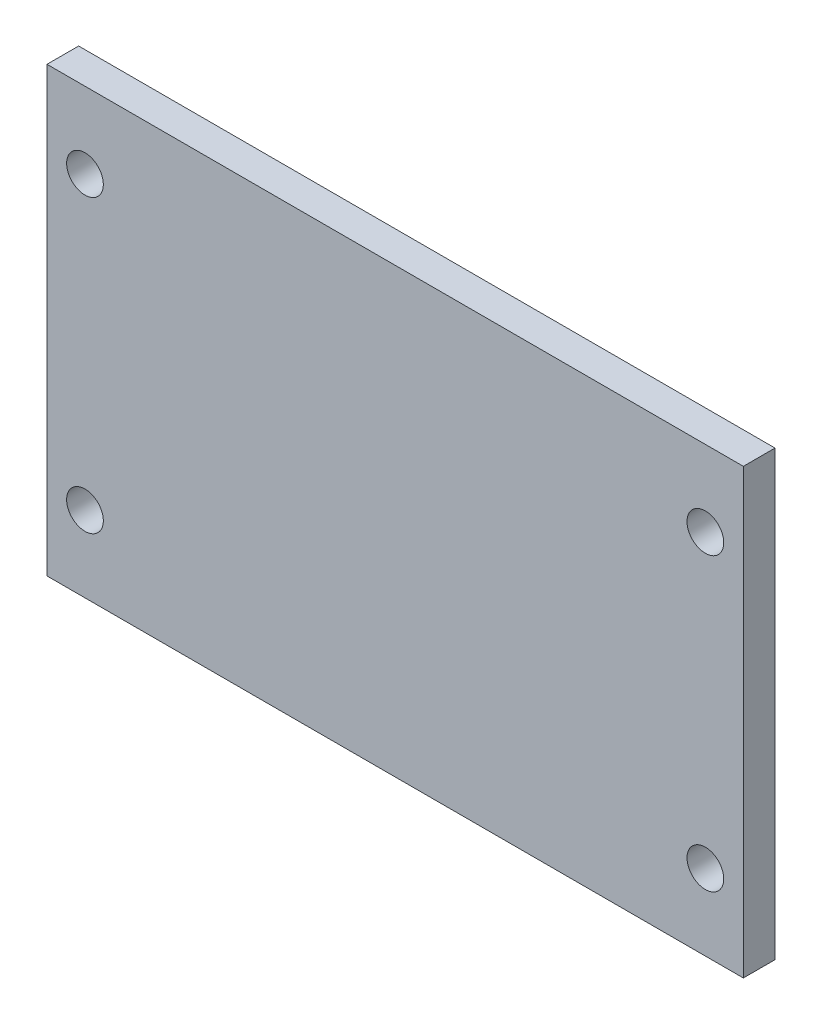
from build123d import *

# Parameters (mm, degrees)
SKETCH1_W            = 110
SKETCH1_H            = 70
BOSS_EXTRUDE1_DEPTH  = 2.5
M5_CLEARANCE_HOLE1_D = 5.8


with BuildPart() as part:
    # Sketch1 → Boss-Extrude1 (new body, symmetric)
    with BuildSketch(Plane.XY):
        Rectangle(SKETCH1_W, SKETCH1_H)
    extrude(amount=BOSS_EXTRUDE1_DEPTH, both=True)

    # M5 Clearance Hole1 (through all)
    with Locations(Plane.XY.offset(2.5)):
        with Locations((-49, 23), (-49, -23), (49, -23), (49, 23)):
            Hole(M5_CLEARANCE_HOLE1_D / 2)


solid = part.part
